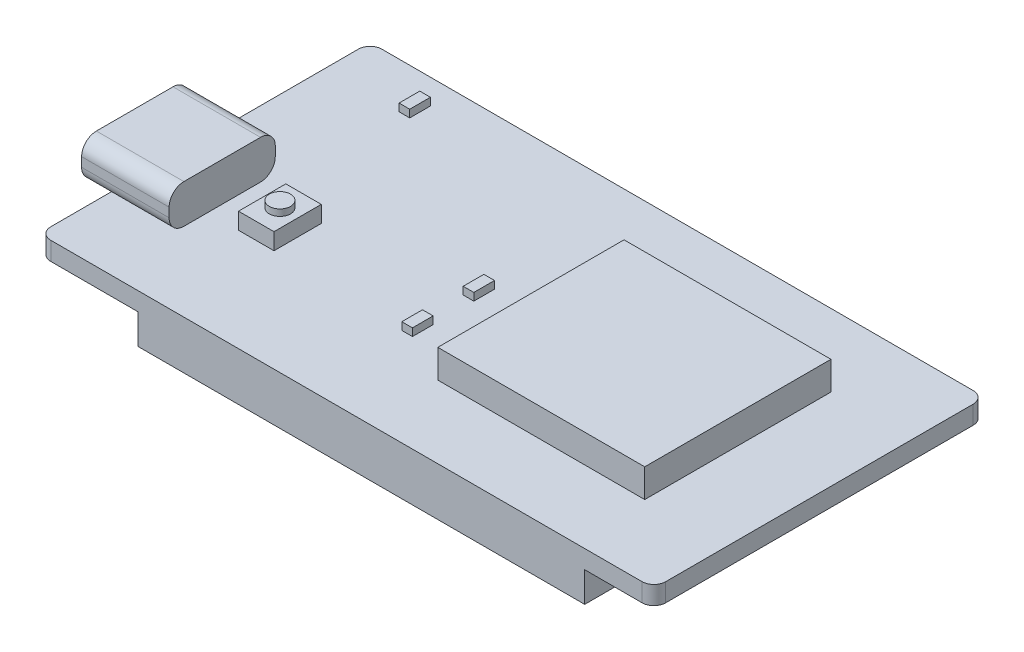
from build123d import *

# Parameters (mm, degrees)
SKETCH_1_W           = 52
SKETCH_1_H           = 28
EXTRUDE_1_DEPTH      = 1.55
FILLET_1_R           = 1
SKETCH_2_W           = 37.76
SKETCH_2_H           = 2.54
EXTRUDE_2_DEPTH      = 2.54
SKETCH_3_W           = 17.5
SKETCH_3_H           = 15.75
EXTRUDE_4_DEPTH      = 2.4
EXTRUDE_6_DEPTH      = 1.8
EXTRUDE_6_DEPTH_BACK = 5.6
SKETCH1_W            = 3
SKETCH1_H            = 4
BOSS_EXTRUDE1_DEPTH  = 1.4
SKETCH1_4_R          = 0.9
BOSS_EXTRUDE2_DEPTH  = 1.95
SKETCH2_W            = 0.9
SKETCH2_H            = 1.75
BOSS_EXTRUDE3_DEPTH  = 0.64


with BuildPart() as part:
    # 草圖1 → 填料-伸長1 (new body)
    with BuildSketch(Plane(origin=(0, 0, 0), x_dir=(1, 0, 0), z_dir=(0, 1, 0))):
        Rectangle(SKETCH_1_W, SKETCH_1_H)
    extrude(amount=EXTRUDE_1_DEPTH)

    # 圓角1
    fillet_1_edges = [part.edges().sort_by_distance(p)[0] for p in [
        (26, 0.775, -14),
        (-26, 0.775, -14),
        (-26, 0.775, 14),
        (26, 0.775, 14),
    ]]
    fillet(fillet_1_edges, radius=FILLET_1_R)

    # 草圖2 → 填料-伸長2 (add)
    with BuildSketch(Plane.XZ):
        with Locations((1.27, 12.73)):
            Rectangle(SKETCH_2_W, SKETCH_2_H)
        with Locations((1.27, -12.73)):
            Rectangle(SKETCH_2_W, SKETCH_2_H)
    extrude(amount=EXTRUDE_2_DEPTH)

    # 草圖3 → 填料-伸長4 (add)
    with BuildSketch(Plane(origin=(0, 1.55, 0), x_dir=(1, 0, 0), z_dir=(0, 1, 0))):
        with Locations((10.35, 0)):
            Rectangle(SKETCH_3_W, SKETCH_3_H)
    extrude(amount=EXTRUDE_4_DEPTH)

    # 草圖5 → 填料-伸長6 (add, two sides: drawn at the far end of the back side and taken through both)
    with BuildSketch(Plane.ZY.offset(26).offset(-EXTRUDE_6_DEPTH_BACK)):
        with BuildLine():
            Line((7.35, 1.55), (0.87, 1.55))
            ThreePointArc((0.87, 1.55), (-0.013883476, 1.916116524), (-0.38, 2.8))
            Line((-0.38, 2.8), (-0.38, 3.58))
            ThreePointArc((-0.38, 3.58), (-0.013883476, 4.463883476), (0.87, 4.83))
            Line((0.87, 4.83), (7.35, 4.83))
            ThreePointArc((7.35, 4.83), (8.233883476, 4.463883476), (8.6, 3.58))
            Line((8.6, 3.58), (8.6, 2.8))
            ThreePointArc((8.6, 2.8), (8.233883476, 1.916116524), (7.35, 1.55))
        make_face()
    extrude(amount=EXTRUDE_6_DEPTH + EXTRUDE_6_DEPTH_BACK)

    # Sketch1 → Boss-Extrude1 (add)
    with BuildSketch(Plane(origin=(0, 1.55, 0), x_dir=(1, 0, 0), z_dir=(0, 1, 0))):
        with Locations((-16.3, -3.33)):
            Rectangle(SKETCH1_W, SKETCH1_H)
    extrude(amount=BOSS_EXTRUDE1_DEPTH)

    # Sketch1_4 → Boss-Extrude2 (add)
    with BuildSketch(Plane(origin=(0, 1.55, 0), x_dir=(1, 0, 0), z_dir=(0, 1, 0))):
        with Locations((-16.3, -3.33)):
            Circle(SKETCH1_4_R)
    extrude(amount=BOSS_EXTRUDE2_DEPTH)

    # Sketch2 → Boss-Extrude3 (add)
    with BuildSketch(Plane(origin=(0, 1.55, 0), x_dir=(1, 0, 0), z_dir=(0, 1, 0))):
        with Locations((-19.24, 11.015)):
            Rectangle(SKETCH2_W, SKETCH2_H)
        with Locations((-3.11, 0.305)):
            Rectangle(SKETCH2_W, SKETCH2_H)
        with Locations((-3.11, -4.885)):
            Rectangle(SKETCH2_W, SKETCH2_H)
    extrude(amount=BOSS_EXTRUDE3_DEPTH)


solid = part.part
